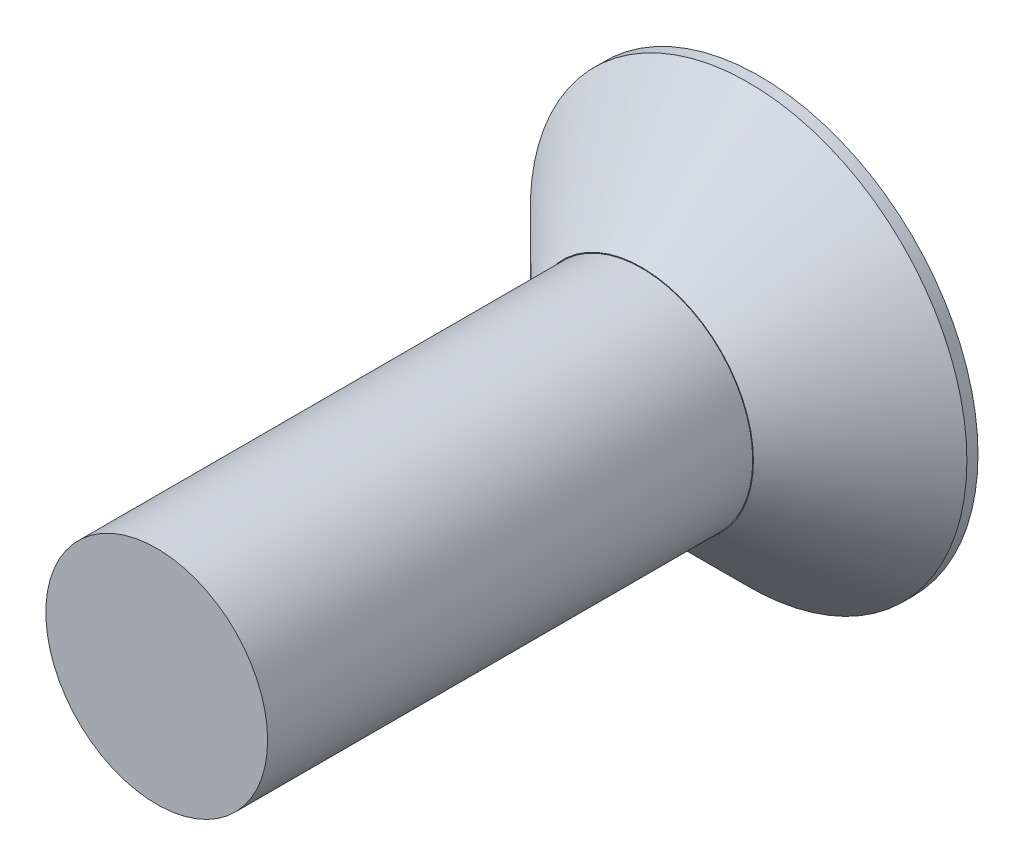
from build123d import *

# Parameters (mm, degrees)
SKETCH1_R      = 4.0005
EXTRUDE1_DEPTH = 2.159
SKETCH2_R      = 2.032
EXTRUDE2_DEPTH = 8.89
EXTRUDE3_DEPTH = 1.016
CHAMFER1_SIZE  = 1.9558


with BuildPart() as part:
    # Sketch1 → Extrude1 (new body)
    with BuildSketch(Plane.XY):
        Circle(SKETCH1_R)
    extrude(amount=EXTRUDE1_DEPTH)

    # Sketch2 → Extrude2 (add)
    with BuildSketch(Plane.XY.offset(2.159)):
        Circle(SKETCH2_R)
    extrude(amount=EXTRUDE2_DEPTH)

    # Sketch3 → Extrude3 (cut)
    with BuildSketch(Plane(origin=(0, 0, 0), x_dir=(-1, 0, 0), z_dir=(0, 0, -1))):
        Polygon((1.206032038, 0.660002963), (0.031436687, 1.374455864), (-1.174595351, 0.714452901), (-1.206032038, -0.660002963), (-0.031436687, -1.374455864), (1.174595351, -0.714452901), align=None)
    extrude(amount=-EXTRUDE3_DEPTH, mode=Mode.SUBTRACT)

    # Chamfer1
    chamfer1_edges = [part.edges().sort_by_distance(p)[0] for p in [
        (-4.0005, 0, 2.159),
    ]]
    chamfer(chamfer1_edges, length=CHAMFER1_SIZE)


solid = part.part
